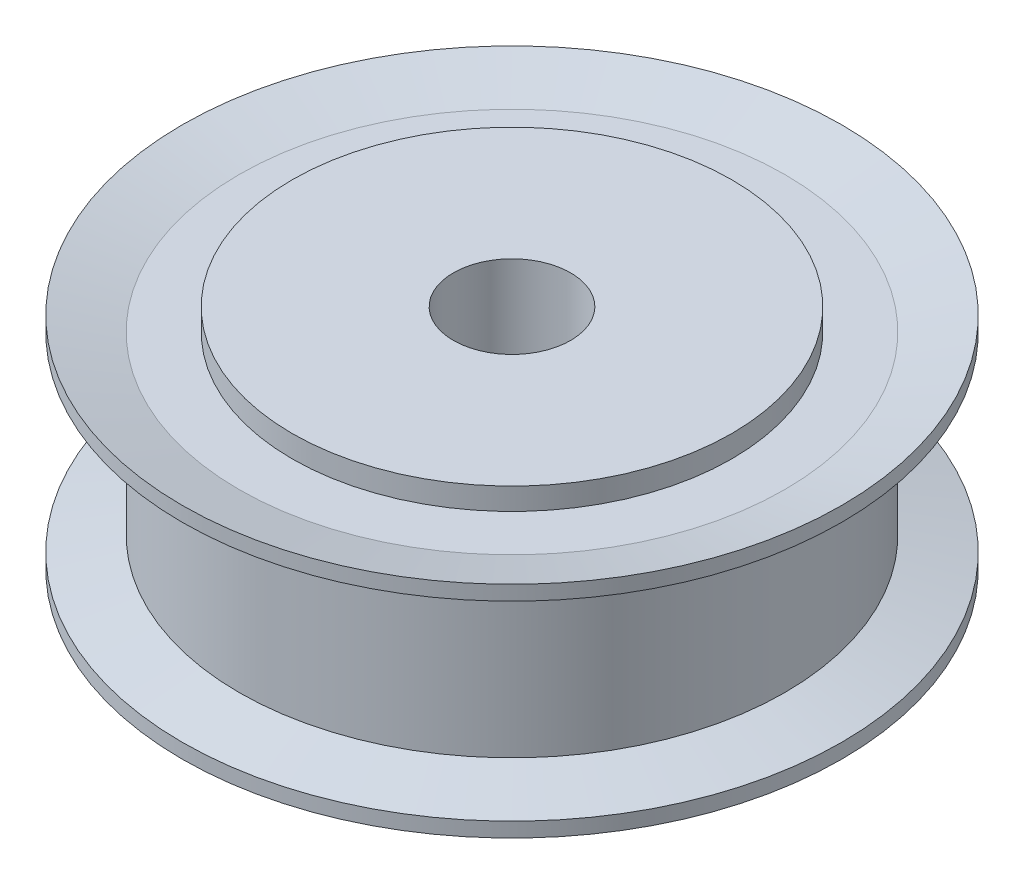
from build123d import *


with BuildPart() as part:
    # 草圖1 → 旋轉1 (revolve)
    with BuildSketch(Plane.XY):
        Polygon((4, -8), (4, 8), (15, 8), (15, 5.5), (18.62, 5.5), (18.62, -5.5), (15, -5.5), (15, -8), align=None)
    revolve(axis=Axis((0, 49.340027701, 0), (0, -1, 0)))

    # 草圖7 → 旋轉2 (revolve)
    with BuildSketch(Plane.XY):
        Polygon((-22.5, -6.5), (-18.62, -5.5), (-15, -5.5), (-15, -6.5), (-18.62, -6.5), (-22.5, -7.5), align=None)
    revolve_2 = revolve(axis=Axis((0, 0, 0), (0, 1, 0)))

    # 鏡射1: 旋轉2 across plane
    add(revolve_2.mirror(Plane.ZX))


solid = part.part
